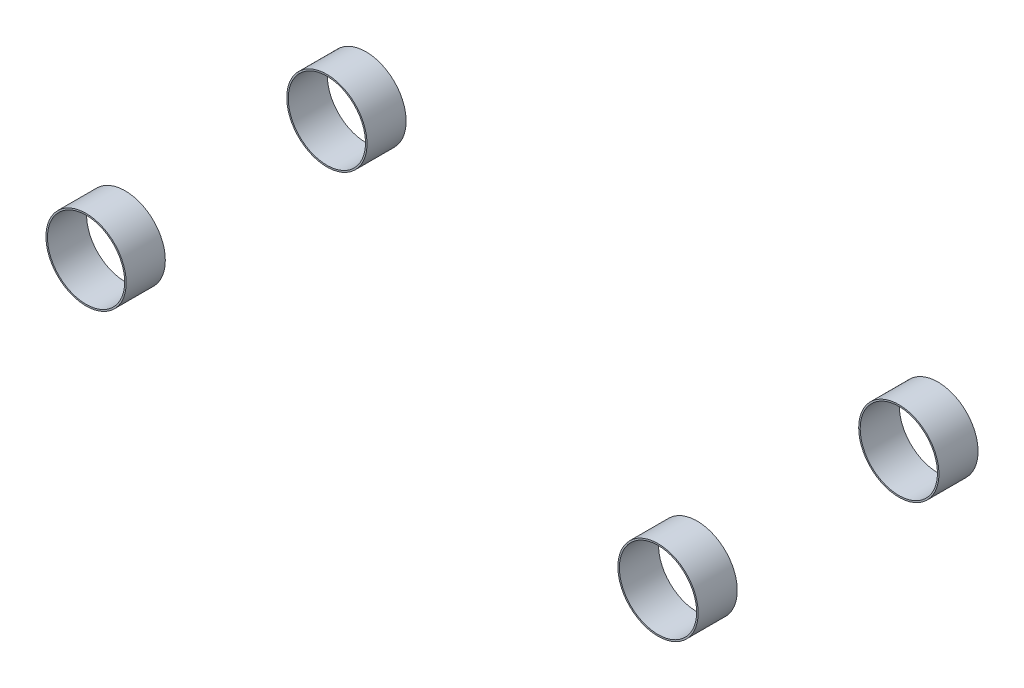
from build123d import *

# Parameters (mm, degrees)
SKETCH3_R             = 200
SKETCH3_R_2           = 192.5
BOSS_EXTRUDE1_DEPTH   = 97.5
BOSS_EXTRUDE1_2_DEPTH = 97.5
SKETCH5_R             = 200
SKETCH5_R_2           = 192.5
BOSS_EXTRUDE2_DEPTH   = 97.5
BOSS_EXTRUDE2_2_DEPTH = 97.5


with BuildPart() as part:
    # Sketch3 → Boss-Extrude1 (new body, symmetric)
    with BuildSketch(Plane.XY.offset(600)):
        with Locations((-1425, 0)):
            Circle(SKETCH3_R)
        with Locations((-1425, 0)):
            Circle(SKETCH3_R_2, mode=Mode.SUBTRACT)
    extrude(amount=BOSS_EXTRUDE1_DEPTH, both=True)


with BuildPart() as body_2:
    # Sketch3 → Boss-Extrude1 2 (new body, symmetric)
    with BuildSketch(Plane.XY.offset(600)):
        with Locations((1425, 0)):
            Circle(SKETCH3_R)
        with Locations((1425, 0)):
            Circle(SKETCH3_R_2, mode=Mode.SUBTRACT)
    extrude(amount=BOSS_EXTRUDE1_2_DEPTH, both=True)


with BuildPart() as body_3:
    # Sketch5 → Boss-Extrude2 (new body, symmetric)
    with BuildSketch(Plane(origin=(0, 0, -600), x_dir=(-1, 0, 0), z_dir=(0, 0, -1))):
        with Locations((-1425, 0)):
            Circle(SKETCH5_R)
        with Locations((-1425, 0)):
            Circle(SKETCH5_R_2, mode=Mode.SUBTRACT)
    extrude(amount=BOSS_EXTRUDE2_DEPTH, both=True)


with BuildPart() as body_4:
    # Sketch5 → Boss-Extrude2 2 (new body, symmetric)
    with BuildSketch(Plane(origin=(0, 0, -600), x_dir=(-1, 0, 0), z_dir=(0, 0, -1))):
        with Locations((1425, 0)):
            Circle(SKETCH5_R)
        with Locations((1425, 0)):
            Circle(SKETCH5_R_2, mode=Mode.SUBTRACT)
    extrude(amount=BOSS_EXTRUDE2_2_DEPTH, both=True)


solid = Compound([part.part, body_2.part, body_3.part, body_4.part])
